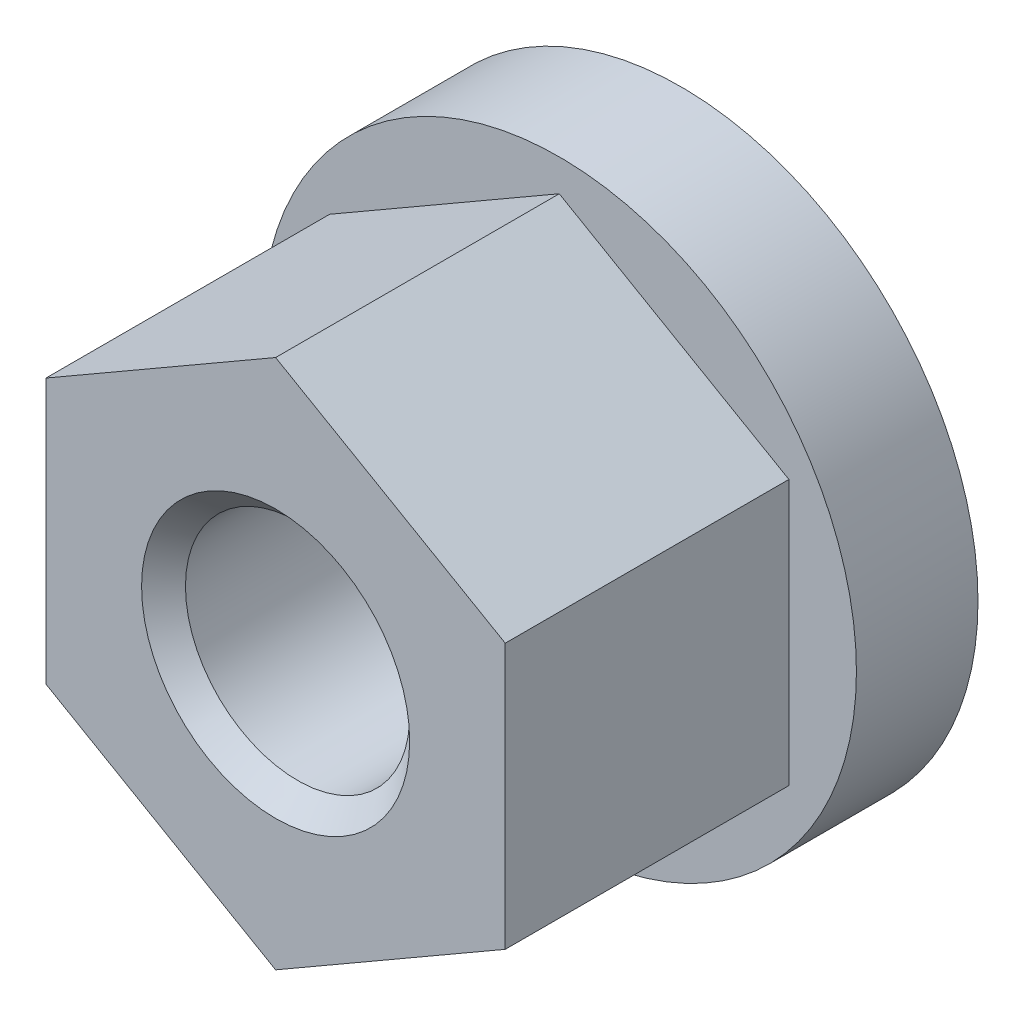
from build123d import *

# Parameters (mm, degrees)
SKETCH_1_W          = 11
SKETCH_1_H          = 4.5
EXTRUDE_1_DEPTH     = 10.5
HOLE_WIZARD_1_D     = 8.3
HOLE_WIZARD_1_DEPTH = 15
CHAMFER_1_SIZE      = 0.812


with BuildPart() as part:
    # 草圖1 → 旋轉1 (revolve)
    with BuildSketch(Plane(origin=(0, 0, 0), x_dir=(1, 0, 0), z_dir=(0, 1, 0))):
        with Locations((5.5, 12.75)):
            Rectangle(SKETCH_1_W, SKETCH_1_H)
    revolve(axis=Axis((0, 0, -15), (0, 0, 1)))

    # 草圖2 → 填料-伸長1 (add)
    with BuildSketch(Plane.XY.offset(-10.5)):
        Polygon((-8.5, -4.907477288), (-8.5, 4.907477288), (0, 9.814954576), (8.5, 4.907477288), (8.5, -4.907477288), (0, -9.814954576), align=None)
    extrude(amount=EXTRUDE_1_DEPTH)

    # 鑽孔1
    with Locations(Plane.XY):
        with Locations((0, 0)):
            Hole(HOLE_WIZARD_1_D / 2, depth=HOLE_WIZARD_1_DEPTH)

    # 導角1
    chamfer_1_edges = [part.edges().sort_by_distance(p)[0] for p in [
        (4.15, 0, 0),
        (4.15, 0, -15),
    ]]
    chamfer(chamfer_1_edges, length=CHAMFER_1_SIZE)


solid = part.part
